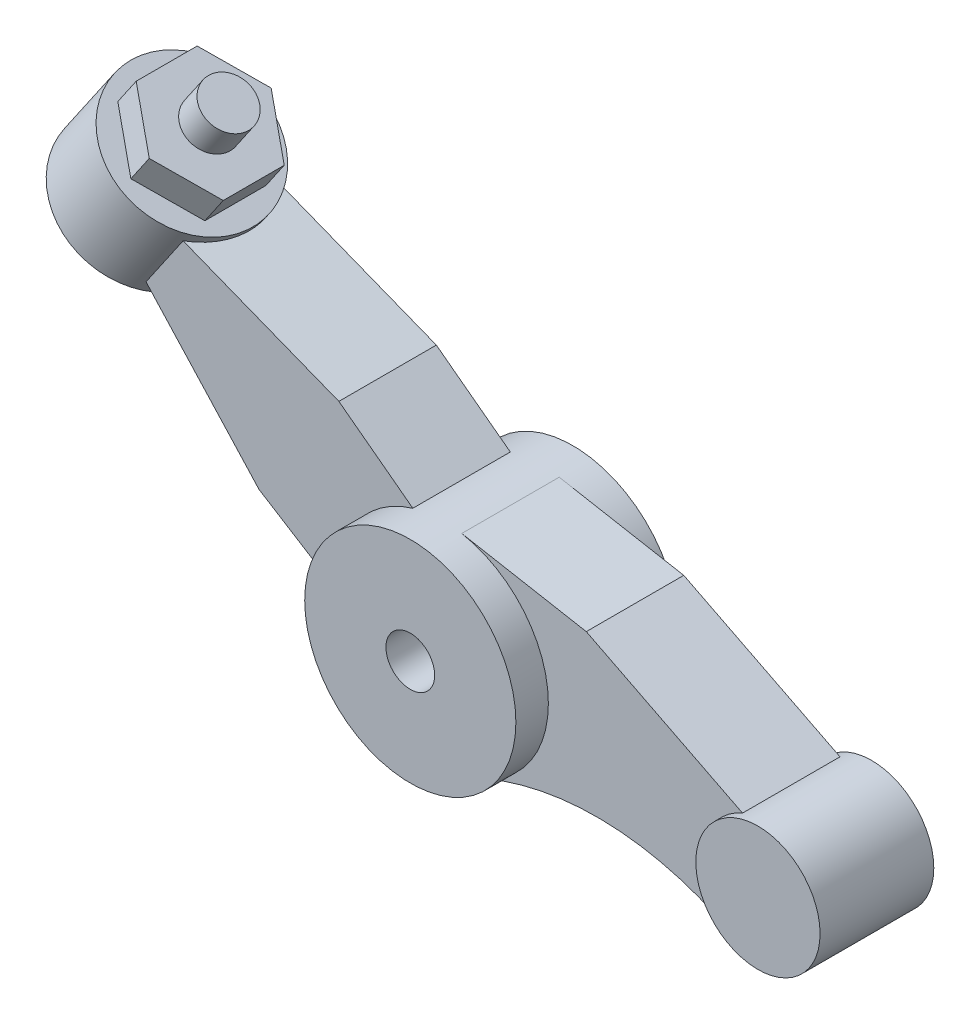
from build123d import *

# Parameters (mm, degrees)
SKETCH1_R           = 0.3
BOSS_EXTRUDE1_DEPTH = 1
BOSS_EXTRUDE2_DEPTH = 0.7
BOSS_EXTRUDE3_DEPTH = 0.6
BOSS_EXTRUDE4_DEPTH = 0.6
BOSS_EXTRUDE5_DEPTH = 0.4
SKETCH6_R           = 0.3
BOSS_EXTRUDE6_DEPTH = 0.4


with BuildPart() as part:
    # Sketch1 → Boss-Extrude1 (new, symmetric)
    with BuildSketch(Plane.XY):
        with BuildLine():
            ThreePointArc((1.3, 0), (0.998317392, 0.832683844), (0.233288639, 1.27889656))
            ThreePointArc((0.233288639, 1.27889656), (-0.069645296, 1.298133095), (-0.368782161, 1.24659525))
            ThreePointArc((-0.368782161, 1.24659525), (-1.071749439, 0.735767042), (-1.295848634, -0.103809043))
            ThreePointArc((-1.295848634, -0.103809043), (-0.6723843, -1.112609255), (0.510625375, -1.195517347))
            ThreePointArc((0.510625375, -1.195517347), (1.084853213, -0.716305456), (1.3, 0))
        make_face()
        Circle(SKETCH1_R, mode=Mode.SUBTRACT)
    extrude(amount=BOSS_EXTRUDE1_DEPTH, both=True)



with BuildPart() as body_2:
    # Sketch1_3 → Boss-Extrude2 (new, symmetric)
    with BuildSketch(Plane.XY):
        with BuildLine():
            ThreePointArc((4.745, -0.682), (4.406355459, -0.046825991), (3.690239158, 0.025999756))
            ThreePointArc((3.690239158, 0.025999756), (3.217046127, -0.626085884), (3.590115999, -1.340191056))
            ThreePointArc((3.590115999, -1.340191056), (4.358790008, -1.346637593), (4.745, -0.682))
        make_face()
    extrude(amount=BOSS_EXTRUDE2_DEPTH, both=True)


with BuildPart() as part_1:
    add(part.part)

    add(body_2.part)  # Boss-Extrude3 merges body 2
    # Sketch1_4 → Boss-Extrude3 (add, symmetric)
    with BuildSketch(Plane.XY):
        with BuildLine():
            ThreePointArc((3.590115999, -1.340191056), (3.217046127, -0.626085884), (3.690239158, 0.025999756))
            Line((3.690239158, 0.025999756), (1.766699303, 0.999180984))
            Line((1.766699303, 0.999180984), (0.233288639, 1.27889656))
            ThreePointArc((0.233288639, 1.27889656), (0.998317392, 0.832683844), (1.3, 0))
            ThreePointArc((1.3, 0), (1.084853213, -0.716305456), (0.510625375, -1.195517347))
            ThreePointArc((0.510625375, -1.195517347), (2.066949931, -0.914952316), (3.590115999, -1.340191056))
        make_face()
    extrude(amount=BOSS_EXTRUDE3_DEPTH, both=True)

    # Sketch1_5 → Boss-Extrude4 (add, symmetric)
    with BuildSketch(Plane.XY):
        with BuildLine():
            ThreePointArc((-1.295848634, -0.103809043), (-1.071749439, 0.735767042), (-0.368782161, 1.24659525))
            Line((-0.368782161, 1.24659525), (-1.279338258, 1.931105297))
            Line((-1.279338258, 1.931105297), (-3.469420101, 2.791170079))
            Line((-3.469420101, 2.791170079), (-3.851452989, 2.234684794))
            Line((-3.851452989, 2.234684794), (-2.261840722, 0.499950592))
            Line((-2.261840722, 0.499950592), (-1.295848634, -0.103809043))
        make_face()
    extrude(amount=BOSS_EXTRUDE4_DEPTH, both=True)



with BuildPart() as body_2_2:
    # Sketch2 → Revolve1 (revolve)
    with BuildSketch(Plane.XY):
        with BuildLine():
            Line((-3.851452989, 2.234684794), (-3.443951242, 2.828269098))
            Line((-3.443951242, 2.828269098), (-3.769598187, 3.051829084))
            Line((-3.769598187, 3.051829084), (-4.833144721, 1.502622153))
            ThreePointArc((-4.833144721, 1.502622153), (-4.430488377, 1.507175235), (-4.298614364, 1.887651393))
            Line((-4.298614364, 1.887651393), (-3.851452989, 2.234684794))
        make_face()
    revolve(axis=Axis((-3.769598187, 3.051829084, 0), (-0.5659746478395021, -0.8244226452511791, 0)))


with BuildPart() as part_2:
    add(part_1.part)

    add(body_2_2.part)  # Revolve2 merges body 2 2
    # Sketch4 → Revolve2 (revolve)
    with BuildSketch(Plane.XY):
        Polygon((-3.68969938, 3.174750981), (-4.303268205, 2.281000641), (-5.053492813, 2.796037571), (-4.439923988, 3.68978791), align=None)
    revolve(axis=Axis((-3.68969938, 3.174750981, 0), (-0.5659746478395026, -0.8244226452511788, 0)))

    # Sketch5 → Boss-Extrude5 (add)
    with BuildSketch(Plane(origin=(0.299434714, 0.436169287, 0), x_dir=(0.8244226452511788, -0.5659746478395026, 0), z_dir=(0.5659746478395026, 0.8244226452511788, 0))):
        Polygon((-4.838700292, 0.75055535), (-5.488700292, 0.375277675), (-5.488700292, -0.375277675), (-4.838700292, -0.75055535), (-4.188700292, -0.375277675), (-4.188700292, 0.375277675), align=None)
    extrude(amount=BOSS_EXTRUDE5_DEPTH)

    # Sketch6 → Boss-Extrude6 (add)
    with BuildSketch(Plane(origin=(0.525824573, 0.765938345, 0), x_dir=(0.8244226452511786, -0.565974647839503, 0), z_dir=(0.565974647839503, 0.8244226452511787, 0))):
        with Locations((-4.838700292, 0)):
            Circle(SKETCH6_R)
    extrude(amount=BOSS_EXTRUDE6_DEPTH)


solid = part_2.part
